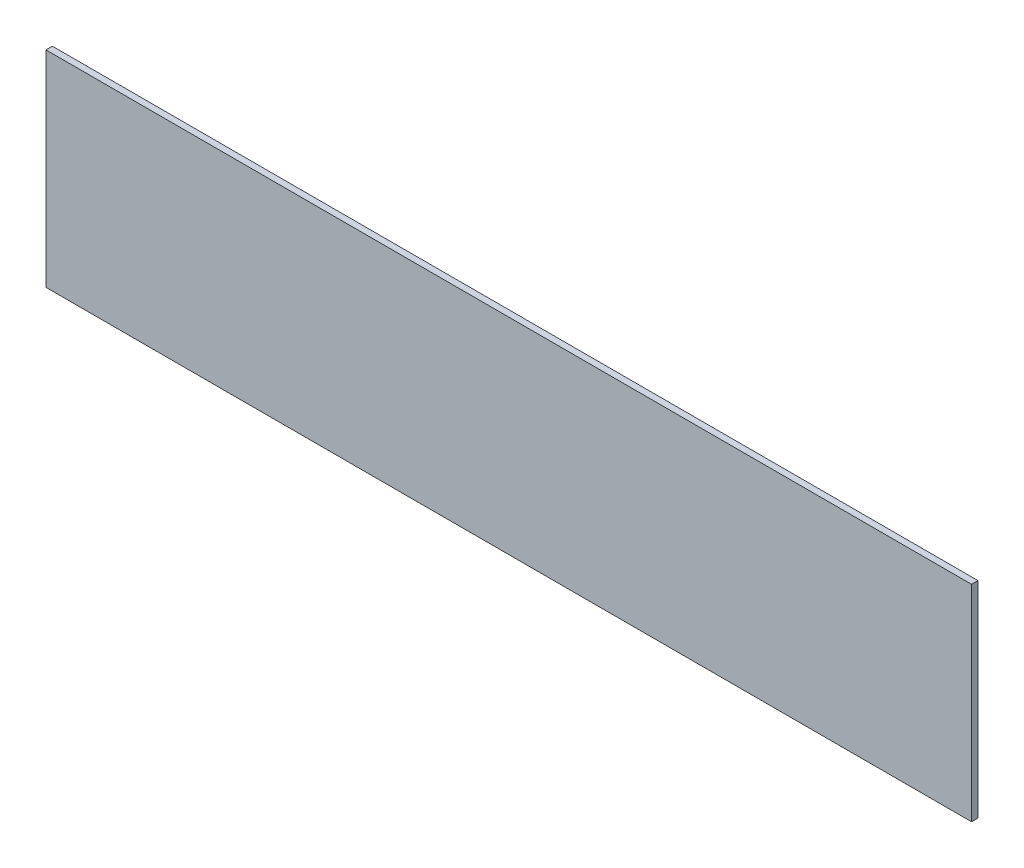
from build123d import *

# Parameters (mm, degrees)
SKETCH1_W           = 228.6
SKETCH1_H           = 50.8
BOSS_EXTRUDE1_DEPTH = 1.5875


with BuildPart() as part:
    # Sketch1 → Boss-Extrude1 (new body)
    with BuildSketch(Plane.XY):
        with Locations((-114.3, -25.4)):
            Rectangle(SKETCH1_W, SKETCH1_H)
    extrude(amount=BOSS_EXTRUDE1_DEPTH)


solid = part.part
